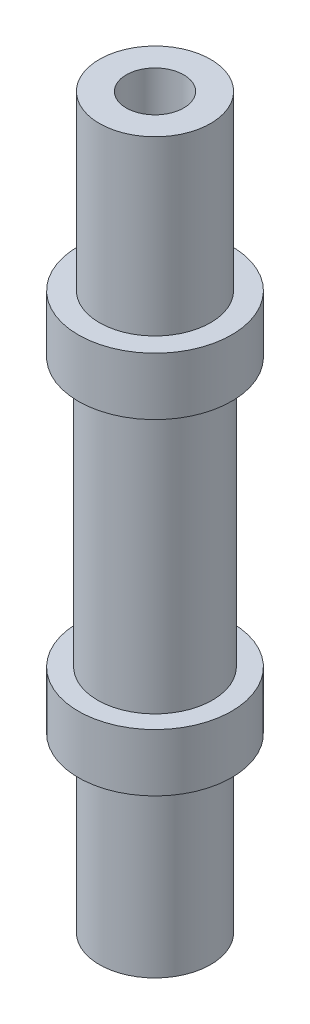
from build123d import *

# Parameters (mm, degrees)
SKETCH1_R           = 3
BOSS_EXTRUDE1_DEPTH = 7
SKETCH2_R           = 4
BOSS_EXTRUDE2_DEPTH = 3
SKETCH3_R           = 4
BOSS_EXTRUDE3_DEPTH = 3
SKETCH4_R           = 2.9
SKETCH4_R_2         = 1.5
BOSS_EXTRUDE5_DEPTH = 9
SKETCH5_R           = 2.9
SKETCH5_R_2         = 1.5
BOSS_EXTRUDE6_DEPTH = 9


with BuildPart() as part:
    # Sketch1 → Boss-Extrude1 (new body, symmetric)
    with BuildSketch(Plane(origin=(0, 0, 0), x_dir=(1, 0, 0), z_dir=(0, 1, 0))):
        Circle(SKETCH1_R)
    extrude(amount=BOSS_EXTRUDE1_DEPTH, both=True)

    # Sketch2 → Boss-Extrude2 (add)
    with BuildSketch(Plane.XZ.offset(7)):
        Circle(SKETCH2_R)
    extrude(amount=BOSS_EXTRUDE2_DEPTH)

    # Sketch3 → Boss-Extrude3 (add)
    with BuildSketch(Plane(origin=(0, 7, 0), x_dir=(1, 0, 0), z_dir=(0, 1, 0))):
        Circle(SKETCH3_R)
    extrude(amount=BOSS_EXTRUDE3_DEPTH)

    # Sketch4 → Boss-Extrude5 (add)
    with BuildSketch(Plane.XZ.offset(10)):
        Circle(SKETCH4_R)
        Circle(SKETCH4_R_2, mode=Mode.SUBTRACT)
    extrude(amount=BOSS_EXTRUDE5_DEPTH)

    # Sketch5 → Boss-Extrude6 (add)
    with BuildSketch(Plane(origin=(0, 10, 0), x_dir=(1, 0, 0), z_dir=(0, 1, 0))):
        Circle(SKETCH5_R)
        Circle(SKETCH5_R_2, mode=Mode.SUBTRACT)
    extrude(amount=BOSS_EXTRUDE6_DEPTH)


solid = part.part
